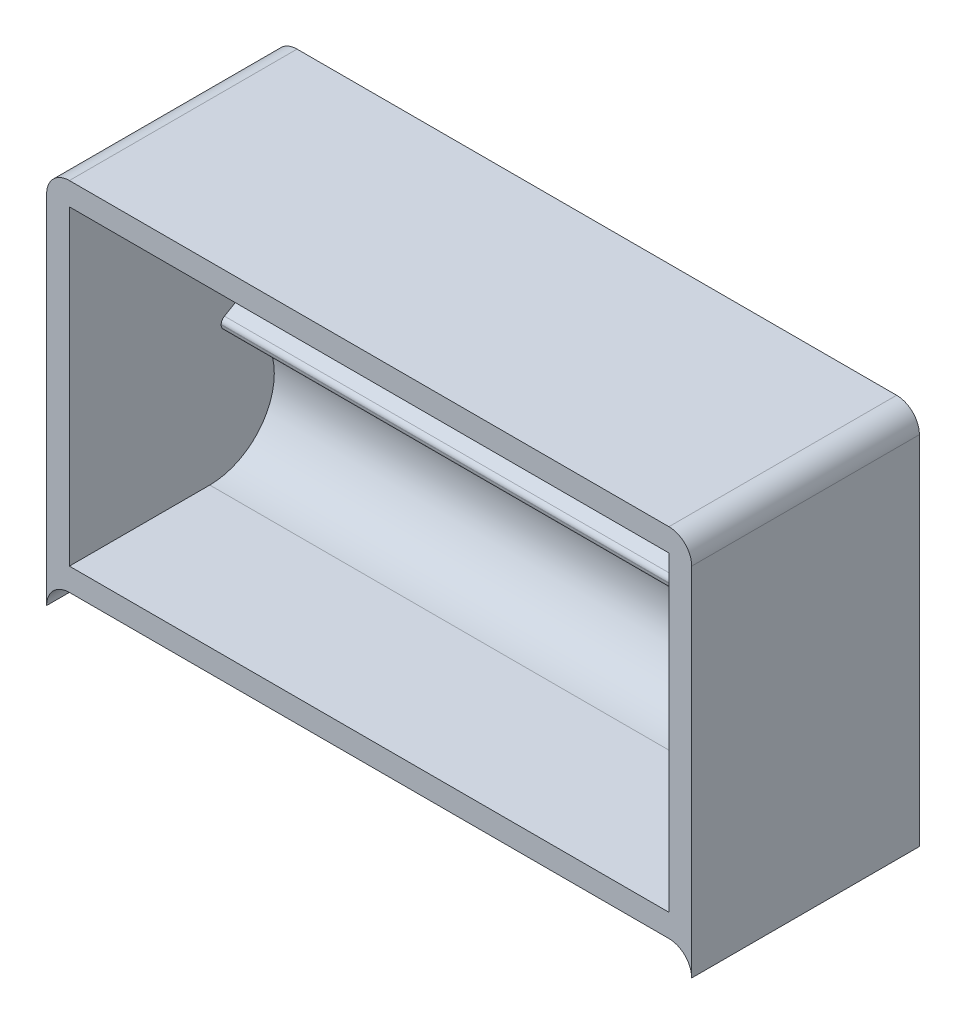
from build123d import *

# Parameters (mm, degrees)
BOSS_EXTRUDE1_DEPTH = 30
CUT_EXTRUDE1_START  = -3
CUT_EXTRUDE1_DEPTH  = 79


with BuildPart() as part:
    # Sketch1 → Boss-Extrude1 (new body)
    with BuildSketch(Plane.XY):
        with BuildLine():
            Line((3, 47), (82, 47))
            ThreePointArc((82, 47), (84.121320344, 46.121320344), (85, 44))
            Line((85, 44), (85, -3))
            ThreePointArc((85, -3), (84.121320344, -0.878679656), (82, 0))
            Line((82, 0), (3, 0))
            ThreePointArc((3, 0), (0.878679656, -0.878679656), (0, -3))
            Line((0, -3), (0, 44))
            ThreePointArc((0, 44), (0.878679656, 46.121320344), (3, 47))
        make_face()
    extrude(amount=BOSS_EXTRUDE1_DEPTH)

    # Sketch2 → Cut-Extrude1 (cut)
    with BuildSketch(Plane(origin=(85, 0, 0), x_dir=(0, 0, -1), z_dir=(1, 0, 0)).offset(CUT_EXTRUDE1_START)):
        with BuildLine():
            Line((-30, 3), (-11.5, 3))
            ThreePointArc((-11.5, 3), (-3.066269455, 10.440665731), (-9.397849462, 19.735955507))
            ThreePointArc((-9.397849462, 19.735955507), (-9.831775106, 20.020329144), (-10, 20.511104261))
            Line((-10, 20.511104261), (-10, 20.58947854))
            ThreePointArc((-10, 20.58947854), (-9.881909085, 21.007808553), (-9.5625, 21.302636131))
            ThreePointArc((-9.5625, 21.302636131), (-3.330202092, 34.795678233), (-15, 44))
            Line((-15, 44), (-30, 44))
            Line((-30, 44), (-30, 3))
        make_face()
    extrude(amount=-CUT_EXTRUDE1_DEPTH, mode=Mode.SUBTRACT)


solid = part.part
